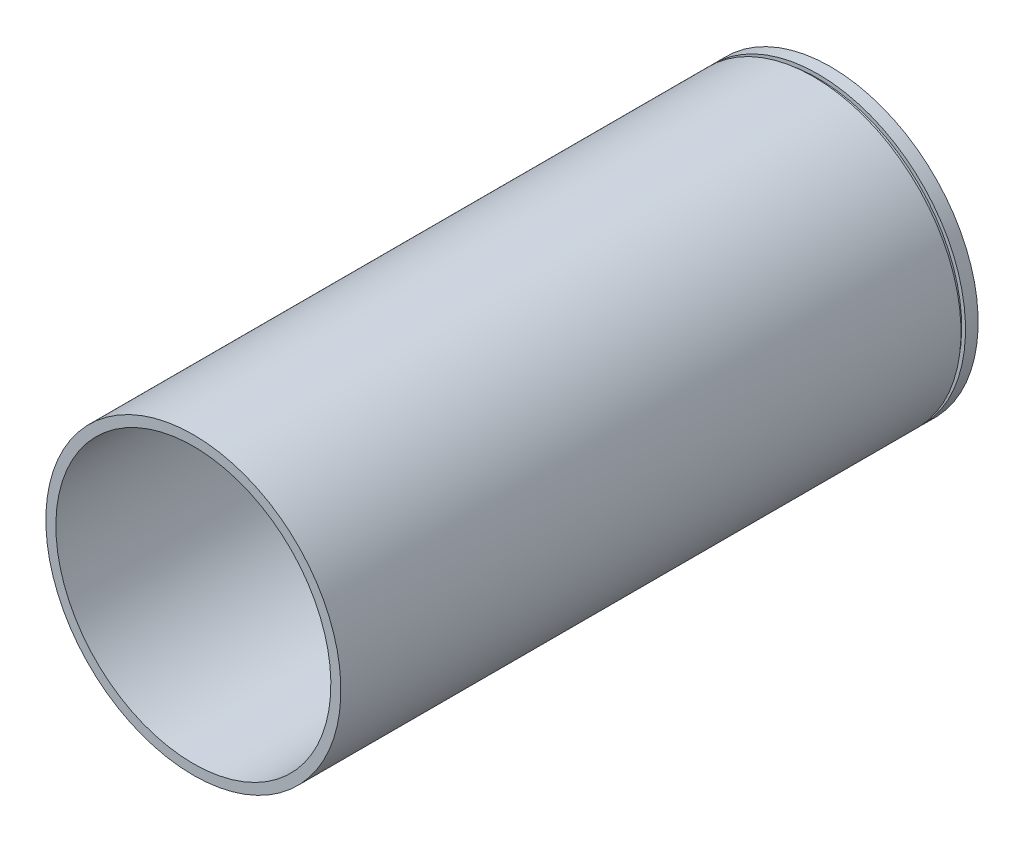
from build123d import *


with BuildPart() as part:
    # Sketch1 → Revolve2 (revolve)
    with BuildSketch(Plane(origin=(0, 0, 0), x_dir=(0, 0, -1), z_dir=(1, 0, 0))):
        Polygon((283.311529954, 136.57), (295, 136.57), (295, 127.3), (-295, 127.3), (-295, 136.57), (279.114653082, 136.57), (279.114653082, 133.049061503), (283.311529954, 133.049061503), align=None)
    revolve(axis=Axis((0, 0, 63.929601425), (0, 0, -1)))


solid = part.part
